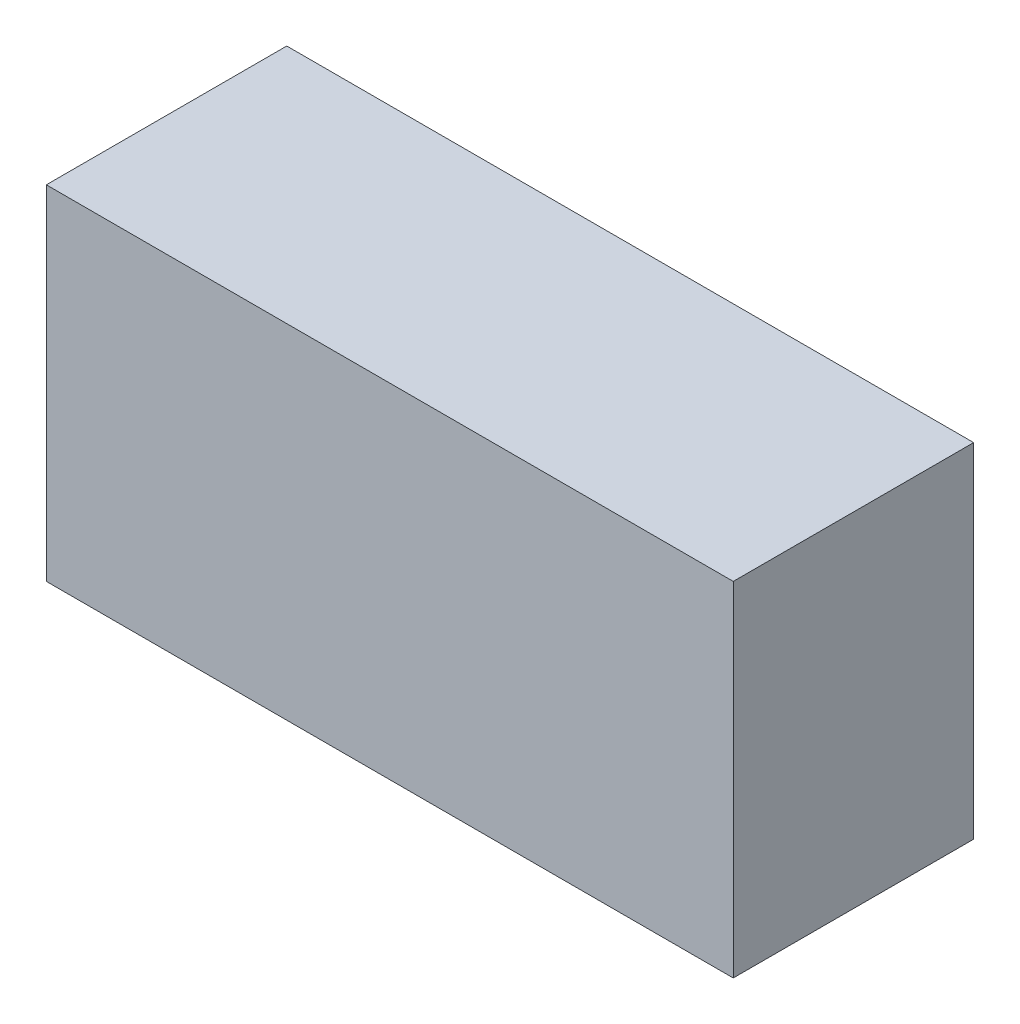
from build123d import *

# Parameters (mm, degrees)
SKETCH1_W           = 1000
SKETCH1_H           = 350
BOSS_EXTRUDE1_DEPTH = 500


with BuildPart() as part:
    # Sketch1 → Boss-Extrude1 (new body)
    with BuildSketch(Plane(origin=(0, 0, 0), x_dir=(1, 0, 0), z_dir=(0, 1, 0))):
        Rectangle(SKETCH1_W, SKETCH1_H)
    extrude(amount=BOSS_EXTRUDE1_DEPTH)


solid = part.part
